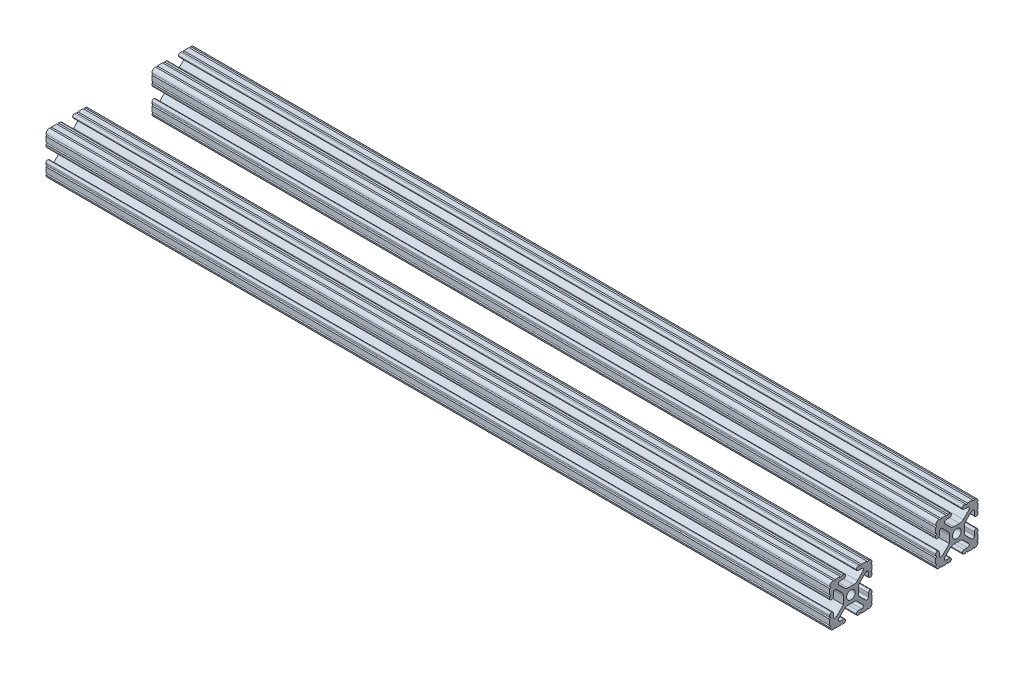
from build123d import *

# Parameters (mm, degrees)
SKETCH1_R                             = 2.6035
F_8020_10_SERIES_1_X_1_X_25_2_DEPTH   = 469.9
SKETCH1_ON_SEGMENT_2_R                = 2.6035
F_8020_10_SERIES_1_X_1_X_25_2_2_DEPTH = 469.9


with BuildPart() as part:
    # Sketch1 → 8020 10 series 1 X 1 X .25(2) (new body)
    with BuildSketch(Plane.ZY):
        with BuildLine():
            Line((6.333126718, -12.7), (9.550443118, -12.7))
            ThreePointArc((9.550443118, -12.7), (10.058366869, -12.192000006), (10.566443095, -12.699847501))
            ThreePointArc((10.566443095, -12.699847501), (12.082537762, -12.08250727), (12.699846982, -10.566399977))
            ThreePointArc((12.699846982, -10.566399977), (12.192000006, -10.058323491), (12.7, -9.5504))
            Line((12.7, -9.5504), (12.7, -6.3330836))
            ThreePointArc((12.7, -6.3330836), (12.192, -5.8250836), (12.7, -5.3170836))
            Line((12.7, -5.3170836), (12.7, -4.287469289))
            ThreePointArc((12.7, -4.287469289), (12.39275138, -3.545705502), (11.650987593, -3.238456882))
            Line((11.650987593, -3.238456882), (11.539212407, -3.238456882))
            ThreePointArc((11.539212407, -3.238456882), (10.79744862, -3.545705502), (10.4902, -4.287469289))
            Line((10.4902, -4.287469289), (10.4902, -6.402089023))
            ThreePointArc((10.4902, -6.402089023), (9.856505071, -7.351067942), (8.737131347, -7.129408934))
            Line((8.737131347, -7.129408934), (4.5085, -2.9104418))
            Line((4.5085, -2.9104418), (4.5085, 1.593185507))
            ThreePointArc((4.5085, 1.593185507), (4.750877967, 2.809883091), (5.441005833, 3.840816462))
            Line((5.441005833, 3.840816462), (8.737131347, 7.129408934))
            ThreePointArc((8.737131347, 7.129408934), (9.856505071, 7.351067942), (10.4902, 6.402089023))
            Line((10.4902, 6.402089023), (10.4902, 4.287469289))
            ThreePointArc((10.4902, 4.287469289), (10.79744862, 3.545705502), (11.539212407, 3.238456882))
            Line((11.539212407, 3.238456882), (11.650987593, 3.238456882))
            ThreePointArc((11.650987593, 3.238456882), (12.39275138, 3.545705502), (12.7, 4.287469289))
            Line((12.7, 4.287469289), (12.7, 5.3170836))
            ThreePointArc((12.7, 5.3170836), (12.192, 5.8250836), (12.7, 6.3330836))
            Line((12.7, 6.3330836), (12.7, 9.5504))
            ThreePointArc((12.7, 9.5504), (12.192000006, 10.058323491), (12.699846982, 10.566399977))
            ThreePointArc((12.699846982, 10.566399977), (12.082537762, 12.08250727), (10.566443095, 12.699847501))
            ThreePointArc((10.566443095, 12.699847501), (10.058366869, 12.192000006), (9.550443118, 12.7))
            Line((9.550443118, 12.7), (6.333126718, 12.7))
            ThreePointArc((6.333126718, 12.7), (5.825126718, 12.192), (5.317126718, 12.7))
            Line((5.317126718, 12.7), (4.287512407, 12.7))
            ThreePointArc((4.287512407, 12.7), (3.54574862, 12.39275138), (3.2385, 11.650987593))
            Line((3.2385, 11.650987593), (3.2385, 11.539212407))
            ThreePointArc((3.2385, 11.539212407), (3.54574862, 10.79744862), (4.287512407, 10.4902))
            Line((4.287512407, 10.4902), (6.476788598, 10.4902))
            ThreePointArc((6.476788598, 10.4902), (7.432222385, 9.85140422), (7.207036008, 8.724370562))
            Line((7.207036008, 8.724370562), (3.898272566, 5.423169045))
            ThreePointArc((3.898272566, 5.423169045), (2.869120213, 4.736787962), (1.655778399, 4.4958))
            Line((1.655778399, 4.4958), (-1.655778399, 4.4958))
            ThreePointArc((-1.655778399, 4.4958), (-2.869120213, 4.736787962), (-3.898272566, 5.423169045))
            Line((-3.898272566, 5.423169045), (-7.207036008, 8.724370562))
            ThreePointArc((-7.207036008, 8.724370562), (-7.432222385, 9.85140422), (-6.476788598, 10.4902))
            Line((-6.476788598, 10.4902), (-4.287512407, 10.4902))
            ThreePointArc((-4.287512407, 10.4902), (-3.54574862, 10.79744862), (-3.2385, 11.539212407))
            Line((-3.2385, 11.539212407), (-3.2385, 11.650987593))
            ThreePointArc((-3.2385, 11.650987593), (-3.54574862, 12.39275138), (-4.287512407, 12.7))
            Line((-4.287512407, 12.7), (-5.317126718, 12.7))
            ThreePointArc((-5.317126718, 12.7), (-5.825126718, 12.192), (-6.333126718, 12.7))
            Line((-6.333126718, 12.7), (-9.550443118, 12.7))
            ThreePointArc((-9.550443118, 12.7), (-10.058366869, 12.192000006), (-10.566443095, 12.699847501))
            ThreePointArc((-10.566443095, 12.699847501), (-12.082537762, 12.08250727), (-12.699846982, 10.566399977))
            ThreePointArc((-12.699846982, 10.566399977), (-12.192000006, 10.058323491), (-12.7, 9.5504))
            Line((-12.7, 9.5504), (-12.7, 6.3330836))
            ThreePointArc((-12.7, 6.3330836), (-12.192, 5.8250836), (-12.7, 5.3170836))
            Line((-12.7, 5.3170836), (-12.7, 4.287469289))
            ThreePointArc((-12.7, 4.287469289), (-12.39275138, 3.545705502), (-11.650987593, 3.238456882))
            Line((-11.650987593, 3.238456882), (-11.539212407, 3.238456882))
            ThreePointArc((-11.539212407, 3.238456882), (-10.79744862, 3.545705502), (-10.4902, 4.287469289))
            Line((-10.4902, 4.287469289), (-10.4902, 6.402089023))
            ThreePointArc((-10.4902, 6.402089023), (-9.856505071, 7.351067942), (-8.737131347, 7.129408934))
            Line((-8.737131347, 7.129408934), (-5.441005833, 3.840816462))
            ThreePointArc((-5.441005833, 3.840816462), (-4.750877967, 2.809883091), (-4.5085, 1.593185507))
            Line((-4.5085, 1.593185507), (-4.5085, -1.593185507))
            ThreePointArc((-4.5085, -1.593185507), (-4.750877967, -2.809883091), (-5.441005833, -3.840816462))
            Line((-5.441005833, -3.840816462), (-8.737131347, -7.129408934))
            ThreePointArc((-8.737131347, -7.129408934), (-9.856505071, -7.351067942), (-10.4902, -6.402089023))
            Line((-10.4902, -6.402089023), (-10.4902, -4.287469289))
            ThreePointArc((-10.4902, -4.287469289), (-10.79744862, -3.545705502), (-11.539212407, -3.238456882))
            Line((-11.539212407, -3.238456882), (-11.650987593, -3.238456882))
            ThreePointArc((-11.650987593, -3.238456882), (-12.39275138, -3.545705502), (-12.7, -4.287469289))
            Line((-12.7, -4.287469289), (-12.7, -5.3170836))
            ThreePointArc((-12.7, -5.3170836), (-12.192, -5.8250836), (-12.7, -6.3330836))
            Line((-12.7, -6.3330836), (-12.7, -9.5504))
            ThreePointArc((-12.7, -9.5504), (-12.192000006, -10.058323491), (-12.699846982, -10.566399977))
            ThreePointArc((-12.699846982, -10.566399977), (-12.082537762, -12.08250727), (-10.566443095, -12.699847501))
            ThreePointArc((-10.566443095, -12.699847501), (-10.058366869, -12.192000006), (-9.550443118, -12.7))
            Line((-9.550443118, -12.7), (-6.333126718, -12.7))
            ThreePointArc((-6.333126718, -12.7), (-5.825126718, -12.192), (-5.317126718, -12.7))
            Line((-5.317126718, -12.7), (-4.287512407, -12.7))
            ThreePointArc((-4.287512407, -12.7), (-3.54574862, -12.39275138), (-3.2385, -11.650987593))
            Line((-3.2385, -11.650987593), (-3.2385, -11.539212407))
            ThreePointArc((-3.2385, -11.539212407), (-3.54574862, -10.79744862), (-4.287512407, -10.4902))
            Line((-4.287512407, -10.4902), (-6.416408329, -10.4902))
            ThreePointArc((-6.416408329, -10.4902), (-7.41473083, -9.822813117), (-7.179650497, -8.645192506))
            Line((-7.179650497, -8.645192506), (-3.952270251, -5.423690499))
            ThreePointArc((-3.952270251, -5.423690499), (-2.922936451, -4.736929036), (-1.709253557, -4.4958))
            Line((-1.709253557, -4.4958), (1.709253557, -4.4958))
            ThreePointArc((1.709253557, -4.4958), (2.922936451, -4.736929036), (3.952270251, -5.423690499))
            Line((3.952270251, -5.423690499), (7.179650497, -8.645192506))
            ThreePointArc((7.179650497, -8.645192506), (7.41473083, -9.822813117), (6.416408329, -10.4902))
            Line((6.416408329, -10.4902), (4.287512407, -10.4902))
            ThreePointArc((4.287512407, -10.4902), (3.54574862, -10.79744862), (3.2385, -11.539212407))
            Line((3.2385, -11.539212407), (3.2385, -11.650987593))
            ThreePointArc((3.2385, -11.650987593), (3.54574862, -12.39275138), (4.287512407, -12.7))
            Line((4.287512407, -12.7), (5.317126718, -12.7))
            ThreePointArc((5.317126718, -12.7), (5.825126718, -12.192), (6.333126718, -12.7))
        make_face()
        Circle(SKETCH1_R, mode=Mode.SUBTRACT)
    extrude(amount=F_8020_10_SERIES_1_X_1_X_25_2_DEPTH)


with BuildPart() as body_2:
    # Sketch1 on segment 2 (carried to segment 2) → 8020 10 series 1 X 1 X .25_2 2 (new body)
    with BuildSketch(Plane(origin=(0, 0, -63.5), x_dir=(0, 0, 1), z_dir=(-1, 0, 0))):
        with BuildLine():
            Line((6.333126718, -12.7), (9.550443118, -12.7))
            ThreePointArc((9.550443118, -12.7), (10.058366869, -12.192000006), (10.566443095, -12.699847501))
            ThreePointArc((10.566443095, -12.699847501), (12.082537762, -12.08250727), (12.699846982, -10.566399977))
            ThreePointArc((12.699846982, -10.566399977), (12.192000006, -10.058323491), (12.7, -9.5504))
            Line((12.7, -9.5504), (12.7, -6.3330836))
            ThreePointArc((12.7, -6.3330836), (12.192, -5.8250836), (12.7, -5.3170836))
            Line((12.7, -5.3170836), (12.7, -4.287469289))
            ThreePointArc((12.7, -4.287469289), (12.39275138, -3.545705502), (11.650987593, -3.238456882))
            Line((11.650987593, -3.238456882), (11.539212407, -3.238456882))
            ThreePointArc((11.539212407, -3.238456882), (10.79744862, -3.545705502), (10.4902, -4.287469289))
            Line((10.4902, -4.287469289), (10.4902, -6.402089023))
            ThreePointArc((10.4902, -6.402089023), (9.856505071, -7.351067942), (8.737131347, -7.129408934))
            Line((8.737131347, -7.129408934), (4.5085, -2.9104418))
            Line((4.5085, -2.9104418), (4.5085, 1.593185507))
            ThreePointArc((4.5085, 1.593185507), (4.750877967, 2.809883091), (5.441005833, 3.840816462))
            Line((5.441005833, 3.840816462), (8.737131347, 7.129408934))
            ThreePointArc((8.737131347, 7.129408934), (9.856505071, 7.351067942), (10.4902, 6.402089023))
            Line((10.4902, 6.402089023), (10.4902, 4.287469289))
            ThreePointArc((10.4902, 4.287469289), (10.79744862, 3.545705502), (11.539212407, 3.238456882))
            Line((11.539212407, 3.238456882), (11.650987593, 3.238456882))
            ThreePointArc((11.650987593, 3.238456882), (12.39275138, 3.545705502), (12.7, 4.287469289))
            Line((12.7, 4.287469289), (12.7, 5.3170836))
            ThreePointArc((12.7, 5.3170836), (12.192, 5.8250836), (12.7, 6.3330836))
            Line((12.7, 6.3330836), (12.7, 9.5504))
            ThreePointArc((12.7, 9.5504), (12.192000006, 10.058323491), (12.699846982, 10.566399977))
            ThreePointArc((12.699846982, 10.566399977), (12.082537762, 12.08250727), (10.566443095, 12.699847501))
            ThreePointArc((10.566443095, 12.699847501), (10.058366869, 12.192000006), (9.550443118, 12.7))
            Line((9.550443118, 12.7), (6.333126718, 12.7))
            ThreePointArc((6.333126718, 12.7), (5.825126718, 12.192), (5.317126718, 12.7))
            Line((5.317126718, 12.7), (4.287512407, 12.7))
            ThreePointArc((4.287512407, 12.7), (3.54574862, 12.39275138), (3.2385, 11.650987593))
            Line((3.2385, 11.650987593), (3.2385, 11.539212407))
            ThreePointArc((3.2385, 11.539212407), (3.54574862, 10.79744862), (4.287512407, 10.4902))
            Line((4.287512407, 10.4902), (6.476788598, 10.4902))
            ThreePointArc((6.476788598, 10.4902), (7.432222385, 9.85140422), (7.207036008, 8.724370562))
            Line((7.207036008, 8.724370562), (3.898272566, 5.423169045))
            ThreePointArc((3.898272566, 5.423169045), (2.869120213, 4.736787962), (1.655778399, 4.4958))
            Line((1.655778399, 4.4958), (-1.655778399, 4.4958))
            ThreePointArc((-1.655778399, 4.4958), (-2.869120213, 4.736787962), (-3.898272566, 5.423169045))
            Line((-3.898272566, 5.423169045), (-7.207036008, 8.724370562))
            ThreePointArc((-7.207036008, 8.724370562), (-7.432222385, 9.85140422), (-6.476788598, 10.4902))
            Line((-6.476788598, 10.4902), (-4.287512407, 10.4902))
            ThreePointArc((-4.287512407, 10.4902), (-3.54574862, 10.79744862), (-3.2385, 11.539212407))
            Line((-3.2385, 11.539212407), (-3.2385, 11.650987593))
            ThreePointArc((-3.2385, 11.650987593), (-3.54574862, 12.39275138), (-4.287512407, 12.7))
            Line((-4.287512407, 12.7), (-5.317126718, 12.7))
            ThreePointArc((-5.317126718, 12.7), (-5.825126718, 12.192), (-6.333126718, 12.7))
            Line((-6.333126718, 12.7), (-9.550443118, 12.7))
            ThreePointArc((-9.550443118, 12.7), (-10.058366869, 12.192000006), (-10.566443095, 12.699847501))
            ThreePointArc((-10.566443095, 12.699847501), (-12.082537762, 12.08250727), (-12.699846982, 10.566399977))
            ThreePointArc((-12.699846982, 10.566399977), (-12.192000006, 10.058323491), (-12.7, 9.5504))
            Line((-12.7, 9.5504), (-12.7, 6.3330836))
            ThreePointArc((-12.7, 6.3330836), (-12.192, 5.8250836), (-12.7, 5.3170836))
            Line((-12.7, 5.3170836), (-12.7, 4.287469289))
            ThreePointArc((-12.7, 4.287469289), (-12.39275138, 3.545705502), (-11.650987593, 3.238456882))
            Line((-11.650987593, 3.238456882), (-11.539212407, 3.238456882))
            ThreePointArc((-11.539212407, 3.238456882), (-10.79744862, 3.545705502), (-10.4902, 4.287469289))
            Line((-10.4902, 4.287469289), (-10.4902, 6.402089023))
            ThreePointArc((-10.4902, 6.402089023), (-9.856505071, 7.351067942), (-8.737131347, 7.129408934))
            Line((-8.737131347, 7.129408934), (-5.441005833, 3.840816462))
            ThreePointArc((-5.441005833, 3.840816462), (-4.750877967, 2.809883091), (-4.5085, 1.593185507))
            Line((-4.5085, 1.593185507), (-4.5085, -1.593185507))
            ThreePointArc((-4.5085, -1.593185507), (-4.750877967, -2.809883091), (-5.441005833, -3.840816462))
            Line((-5.441005833, -3.840816462), (-8.737131347, -7.129408934))
            ThreePointArc((-8.737131347, -7.129408934), (-9.856505071, -7.351067942), (-10.4902, -6.402089023))
            Line((-10.4902, -6.402089023), (-10.4902, -4.287469289))
            ThreePointArc((-10.4902, -4.287469289), (-10.79744862, -3.545705502), (-11.539212407, -3.238456882))
            Line((-11.539212407, -3.238456882), (-11.650987593, -3.238456882))
            ThreePointArc((-11.650987593, -3.238456882), (-12.39275138, -3.545705502), (-12.7, -4.287469289))
            Line((-12.7, -4.287469289), (-12.7, -5.3170836))
            ThreePointArc((-12.7, -5.3170836), (-12.192, -5.8250836), (-12.7, -6.3330836))
            Line((-12.7, -6.3330836), (-12.7, -9.5504))
            ThreePointArc((-12.7, -9.5504), (-12.192000006, -10.058323491), (-12.699846982, -10.566399977))
            ThreePointArc((-12.699846982, -10.566399977), (-12.082537762, -12.08250727), (-10.566443095, -12.699847501))
            ThreePointArc((-10.566443095, -12.699847501), (-10.058366869, -12.192000006), (-9.550443118, -12.7))
            Line((-9.550443118, -12.7), (-6.333126718, -12.7))
            ThreePointArc((-6.333126718, -12.7), (-5.825126718, -12.192), (-5.317126718, -12.7))
            Line((-5.317126718, -12.7), (-4.287512407, -12.7))
            ThreePointArc((-4.287512407, -12.7), (-3.54574862, -12.39275138), (-3.2385, -11.650987593))
            Line((-3.2385, -11.650987593), (-3.2385, -11.539212407))
            ThreePointArc((-3.2385, -11.539212407), (-3.54574862, -10.79744862), (-4.287512407, -10.4902))
            Line((-4.287512407, -10.4902), (-6.416408329, -10.4902))
            ThreePointArc((-6.416408329, -10.4902), (-7.41473083, -9.822813117), (-7.179650497, -8.645192506))
            Line((-7.179650497, -8.645192506), (-3.952270251, -5.423690499))
            ThreePointArc((-3.952270251, -5.423690499), (-2.922936451, -4.736929036), (-1.709253557, -4.4958))
            Line((-1.709253557, -4.4958), (1.709253557, -4.4958))
            ThreePointArc((1.709253557, -4.4958), (2.922936451, -4.736929036), (3.952270251, -5.423690499))
            Line((3.952270251, -5.423690499), (7.179650497, -8.645192506))
            ThreePointArc((7.179650497, -8.645192506), (7.41473083, -9.822813117), (6.416408329, -10.4902))
            Line((6.416408329, -10.4902), (4.287512407, -10.4902))
            ThreePointArc((4.287512407, -10.4902), (3.54574862, -10.79744862), (3.2385, -11.539212407))
            Line((3.2385, -11.539212407), (3.2385, -11.650987593))
            ThreePointArc((3.2385, -11.650987593), (3.54574862, -12.39275138), (4.287512407, -12.7))
            Line((4.287512407, -12.7), (5.317126718, -12.7))
            ThreePointArc((5.317126718, -12.7), (5.825126718, -12.192), (6.333126718, -12.7))
        make_face()
        Circle(SKETCH1_ON_SEGMENT_2_R, mode=Mode.SUBTRACT)
    extrude(amount=F_8020_10_SERIES_1_X_1_X_25_2_2_DEPTH)


solid = Compound([part.part, body_2.part])
